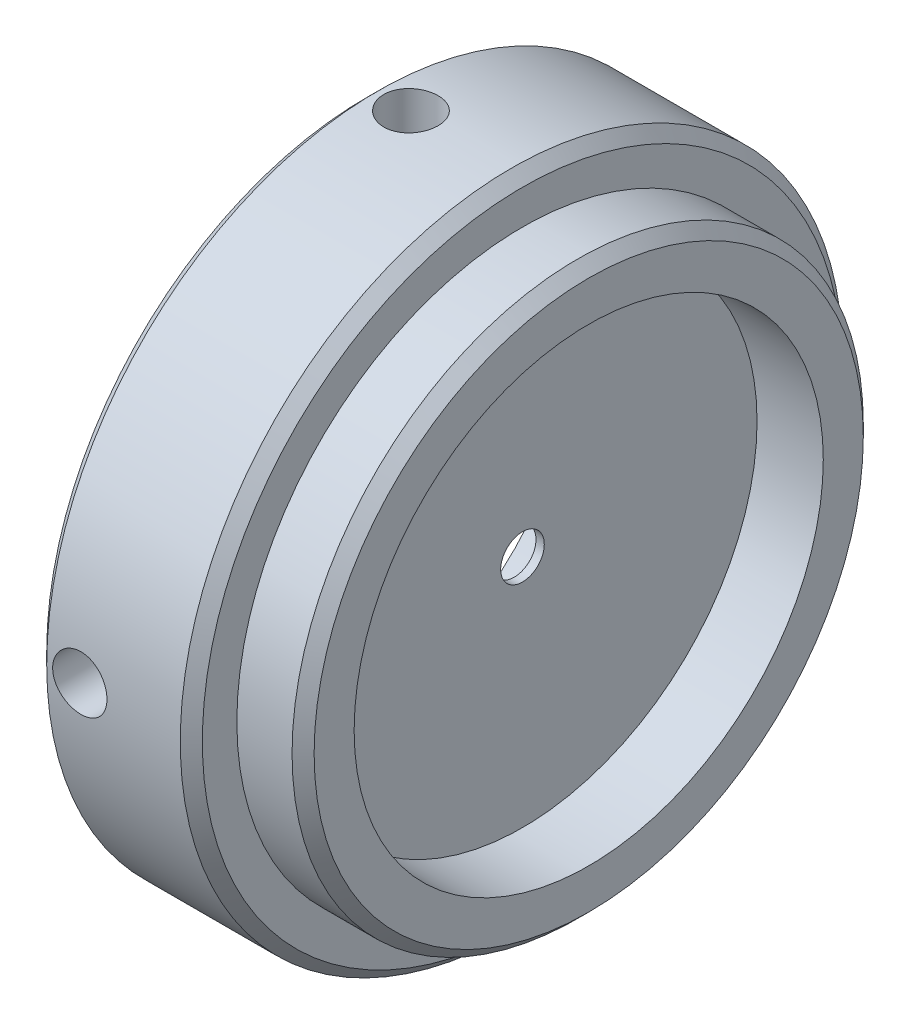
from build123d import *

# Parameters (mm, degrees)
M3X0_5_TAPPED_HOLE1_REACH           = 32.48
M3X0_5_TAPPED_HOLE1_BORE_R          = 1.25
M3X0_5_TAPPED_HOLE1_ON_FACE_2_REACH = 32.48
M3X0_5_TAPPED_HOLE1_BORE_2_R        = 1.25
CHAMFER1_SIZE                       = 0.508


with BuildPart() as part:
    # Sketch1 → Revolve1 (revolve)
    with BuildSketch(Plane.XY, mode=Mode.PRIVATE) as revolve1_sk:
        Polygon((-0.381, 1.0033), (-3.0988, 5.710667685), (-3.0988, 9.525), (-7.1628, 9.525), (-7.1628, 15.24), (0, 15.24), (0, 13.1445), (3.048, 13.1445), (3.048, 10.795), (0, 10.795), (0, 1.0033), align=None)
    revolve(revolve1_sk.sketch.rotate(Axis((0, 0, 0), (-1, 0, 0)), 90), axis=Axis((0, 0, 0), (-1, 0, 0)))  # turned: the seam where the file's is

    # M3x0.5 Tapped Hole1 bore (on position points) → M3x0.5 Tapped Hole1 (cut, up to next)
    with BuildSketch(Plane(origin=(-5.1308, 15.24, 0), x_dir=(0, 0, 1), z_dir=(0, 1, 0)), mode=Mode.PRIVATE) as m3x0_5_tapped_hole1_sk1:
        Circle(M3X0_5_TAPPED_HOLE1_BORE_R)
    m3x0_5_tapped_hole1_tool1 = extrude(m3x0_5_tapped_hole1_sk1.sketch, amount=-M3X0_5_TAPPED_HOLE1_REACH, mode=Mode.PRIVATE) & part.part
    add(m3x0_5_tapped_hole1_tool1.solids().sort_by_distance((-5.1308, 15.24, 0))[0], mode=Mode.SUBTRACT)

    # M3x0.5 Tapped Hole1 bore 2 (on position points) → M3x0.5 Tapped Hole1 on face 2 (cut, up to next)
    with BuildSketch(Plane(origin=(-5.1308, 0, 15.24), x_dir=(1, 0, 0), z_dir=(0, 0, 1)), mode=Mode.PRIVATE) as m3x0_5_tapped_hole1_on_face_2_sk1:
        Circle(M3X0_5_TAPPED_HOLE1_BORE_2_R)
    m3x0_5_tapped_hole1_on_face_2_tool1 = extrude(m3x0_5_tapped_hole1_on_face_2_sk1.sketch, amount=-M3X0_5_TAPPED_HOLE1_ON_FACE_2_REACH, mode=Mode.PRIVATE) & part.part
    add(m3x0_5_tapped_hole1_on_face_2_tool1.solids().sort_by_distance((-5.1308, 0, 15.24))[0], mode=Mode.SUBTRACT)

    # Chamfer1
    chamfer1_edges = [part.edges().sort_by_distance(p)[0] for p in [
        (-7.1628, 0, 15.24),
        (0, 0, 15.24),
        (3.048, 0, 13.1445),
    ]]
    chamfer(chamfer1_edges, length=CHAMFER1_SIZE)


solid = part.part
